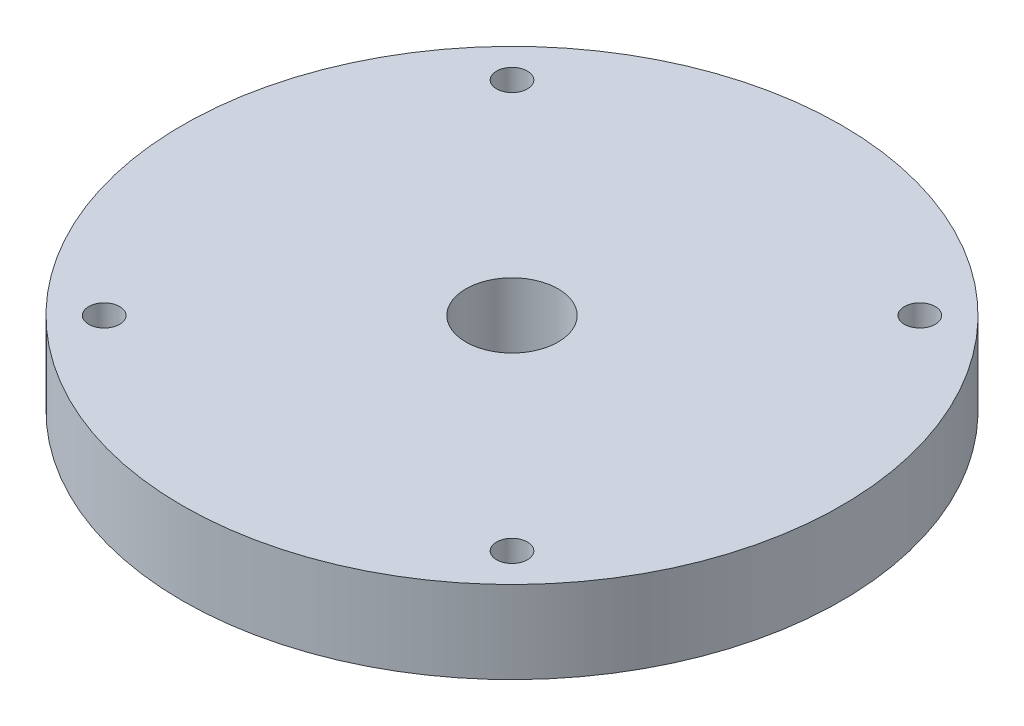
from build123d import *

# Parameters (mm, degrees)
SKETCH1_R           = 25.4
SKETCH1_R_2         = 1.190625
SKETCH1_R_3         = 3.556
BOSS_EXTRUDE1_DEPTH = 6.35


with BuildPart() as part:
    # Sketch1 → Boss-Extrude1 (new body)
    with BuildSketch(Plane(origin=(0, 0, 0), x_dir=(1, 0, 0), z_dir=(0, 1, 0))):
        Circle(SKETCH1_R)
        with Locations((-15.715448212, 15.715448212)):
            Circle(SKETCH1_R_2, mode=Mode.SUBTRACT)
        with Locations((15.715448212, 15.715448212)):
            Circle(SKETCH1_R_2, mode=Mode.SUBTRACT)
        with Locations((15.715448212, -15.715448212)):
            Circle(SKETCH1_R_2, mode=Mode.SUBTRACT)
        with Locations((-15.715448212, -15.715448212)):
            Circle(SKETCH1_R_2, mode=Mode.SUBTRACT)
        Circle(SKETCH1_R_3, mode=Mode.SUBTRACT)
    extrude(amount=BOSS_EXTRUDE1_DEPTH)


solid = part.part
